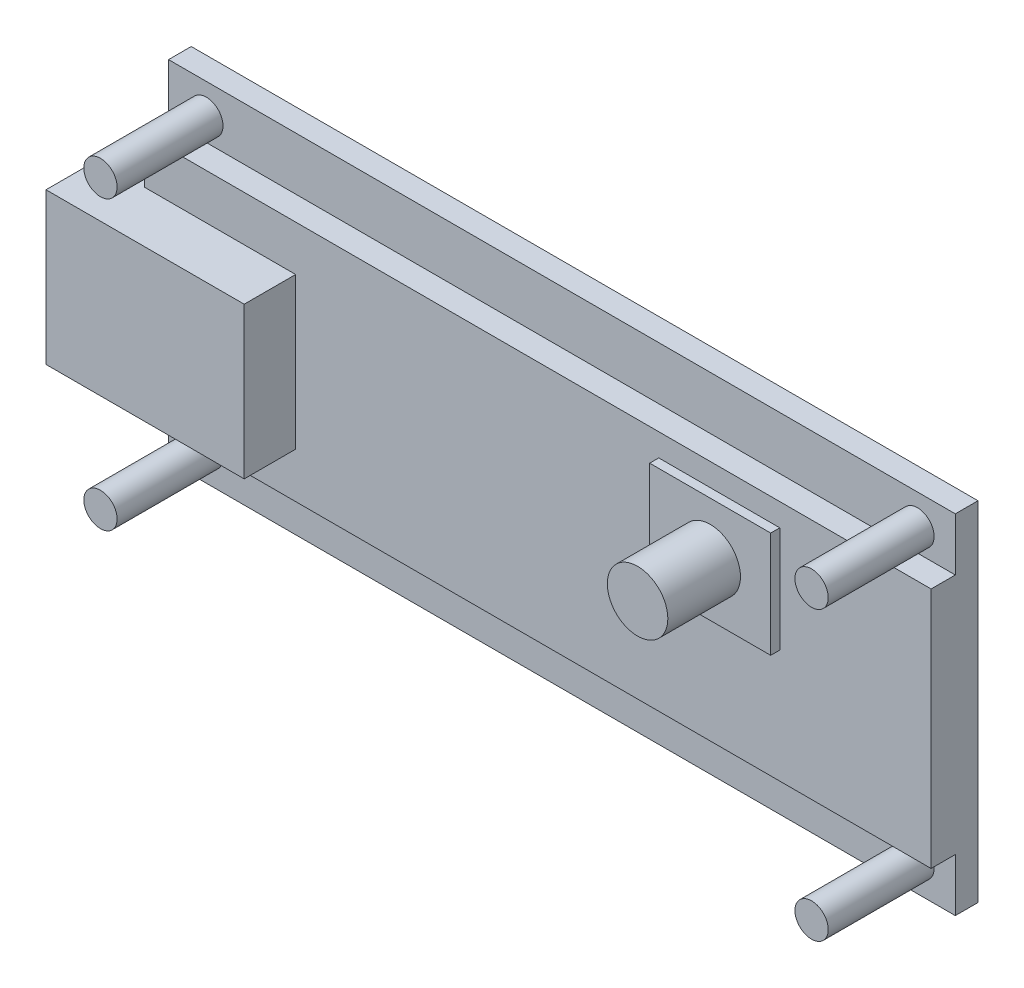
from build123d import *

# Parameters (mm, degrees)
SKETCH1_W                  = 52
SKETCH1_H                  = 23
SKETCH1_R                  = 1.1
EXT_PCB_DEPTH              = 1.5
SKETCH2_W                  = 11.1
SKETCH2_H                  = 10
EXT_USB_SOCKET_DEPTH       = 5
SKETCH3_W                  = 52
SKETCH3_H                  = 16
EXT_COMPONENTS_DEPTH       = 1.6
SKETCH4_W                  = 8
SKETCH4_H                  = 7
EXT_RESET_BUTTON_DEPTH     = 2.2
SKETCH4_3_R                = 2
EXT_RESET_BUTTON_PEG_DEPTH = 7
SKETCH5_W                  = 4.4
SKETCH5_H                  = 9.4
EXT_USB_PLUG_DEPTH         = 2
SKETCH6_W                  = 1.5
SKETCH6_H                  = 10
EXT_USB_SLOT_DEPTH         = 3.1
EXT_START                  = -1.5
SKETCH7_R                  = 1.1
EXT_MOUNTS_DEPTH           = 8.5


with BuildPart() as part:
    # Sketch1 → ext PCB (new body)
    with BuildSketch(Plane.XY):
        with Locations((26, 11.5)):
            Rectangle(SKETCH1_W, SKETCH1_H)
        with Locations((2.5, 21)):
            Circle(SKETCH1_R, mode=Mode.SUBTRACT)
        with Locations((49.5, 21)):
            Circle(SKETCH1_R, mode=Mode.SUBTRACT)
        with Locations((2.5, 2)):
            Circle(SKETCH1_R, mode=Mode.SUBTRACT)
        with Locations((49.5, 2)):
            Circle(SKETCH1_R, mode=Mode.SUBTRACT)
    extrude(amount=-EXT_PCB_DEPTH)

    # Sketch2 → ext USB socket (add)
    with BuildSketch(Plane.XY):
        with Locations((4.45, 11.5)):
            Rectangle(SKETCH2_W, SKETCH2_H)
    extrude(amount=EXT_USB_SOCKET_DEPTH)

    # Sketch3 → ext Components (add)
    with BuildSketch(Plane.XY):
        with Locations((26, 11.5)):
            Rectangle(SKETCH3_W, SKETCH3_H)
    extrude(amount=EXT_COMPONENTS_DEPTH)

    # Sketch4 → ext Reset button (add)
    with BuildSketch(Plane.XY):
        with Locations((38, 14.5)):
            Rectangle(SKETCH4_W, SKETCH4_H)
    extrude(amount=EXT_RESET_BUTTON_DEPTH)

    # Sketch4_3 → ext Reset Button Peg (add)
    with BuildSketch(Plane.XY):
        with Locations((38, 14.5)):
            Circle(SKETCH4_3_R)
    extrude(amount=EXT_RESET_BUTTON_PEG_DEPTH)

    # Sketch5 → ext USB Plug (add)
    with BuildSketch(Plane.ZY.offset(1.1)):
        with Locations((2.5, 11.5)):
            Rectangle(SKETCH5_W, SKETCH5_H)
    extrude(amount=EXT_USB_PLUG_DEPTH)

    # Sketch6 → ext USB slot (add)
    with BuildSketch(Plane.ZY):
        Polygon((1.6, 6.5), (5, 6.5), (5, 16.5), (1.6, 16.5), (0, 16.5), (0, 6.5), align=None)
        with Locations((-0.75, 11.5)):
            Rectangle(SKETCH6_W, SKETCH6_H)
    extrude(amount=EXT_USB_SLOT_DEPTH)

    # Sketch7 → ext Mounts (add)
    with BuildSketch(Plane.XY.offset(EXT_START)):
        with Locations((49.5, 2)):
            Circle(SKETCH7_R)
        with Locations((2.5, 2)):
            Circle(SKETCH7_R)
        with Locations((2.5, 21)):
            Circle(SKETCH7_R)
        with Locations((49.5, 21)):
            Circle(SKETCH7_R)
    extrude(amount=EXT_MOUNTS_DEPTH)


solid = part.part
